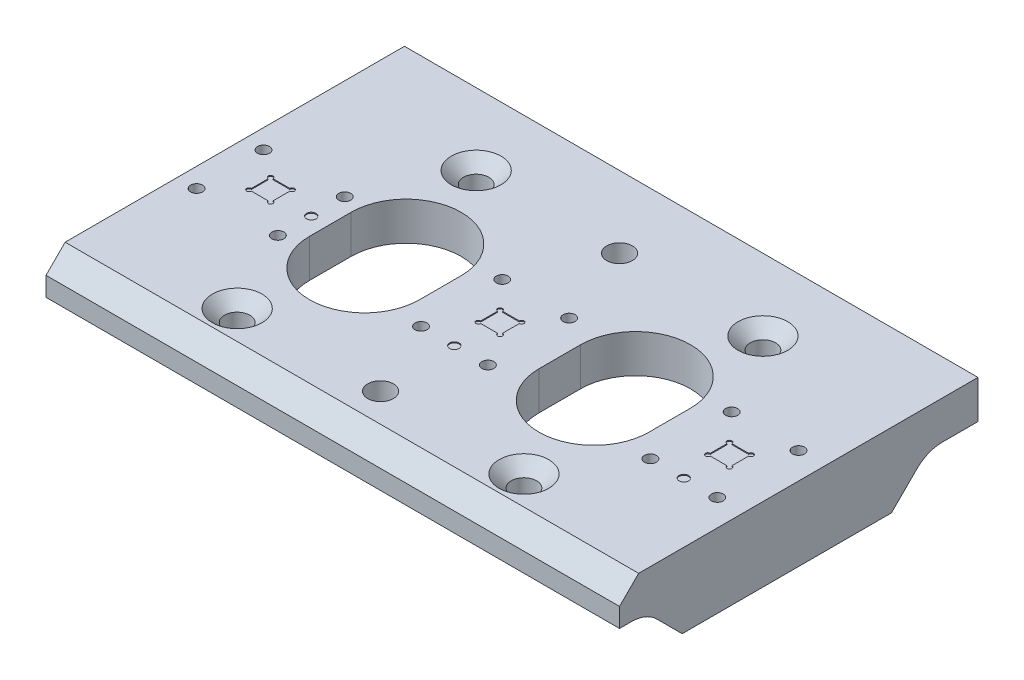
from build123d import *

# Parameters (mm, degrees)
SKETCH_5_W                  = 120
SKETCH_5_H                  = 75
EXTRUDE_2_DEPTH             = 8
SKETCH2_R                   = 1
CUT_EXTRUDE2_DEPTH          = 0.2
M3X0_5_TAPPED_HOLE1_D       = 2.5
M3X0_5_TAPPED_HOLE1_DEPTH   = 5.5
M3X0_5_TAPPED_HOLE1_TIP     = 0.751075774
HOLE_WIZARD_M51_D           = 5.3
HOLE_WIZARD_M51_CSINK_D     = 10.4
HOLE_WIZARD_M51_CSINK_ANGLE = 90
SKETCH5_R                   = 2.6
CUT_EXTRUDE3_DEPTH          = 9
CUT_EXTRUDE3_TAPER          = -0.573055556
CUT_EXTRUDE_1_DEPTH         = 10
EXTRUDE_3_DEPTH             = 120
SKETCH_8_W                  = 92
SKETCH_8_H                  = 31.175411479
CUT_EXTRUDE_2_DEPTH         = 76
CHAMFER_1_SIZE              = 4


with BuildPart() as part:
    # Эскиз5 → Бобышка-Вытянуть2 (new body)
    with BuildSketch(Plane(origin=(0, 0, 0), x_dir=(1, 0, 0), z_dir=(0, 1, 0))):
        with Locations((60, 2.5)):
            Rectangle(SKETCH_5_W, SKETCH_5_H)
    extrude(amount=-EXTRUDE_2_DEPTH)

    # Sketch2 → Cut-Extrude2 (cut)
    with BuildSketch(Plane(origin=(0, 0, 0), x_dir=(1, 0, 0), z_dir=(0, 1, 0))):
        with Locations((59.481, -9.027)):
            Circle(SKETCH2_R)
        with Locations((21.027, -0.519)):
            Circle(SKETCH2_R)
        with Locations((107.481, -9.027)):
            Circle(SKETCH2_R)
        with BuildLine():
            Line((106.24, -2.26), (109.76, -2.26))
            ThreePointArc((109.76, -2.26), (110.613553391, -2.613553391), (110.26, -1.76))
            Line((110.26, -1.76), (110.26, 1.76))
            ThreePointArc((110.26, 1.76), (110.613553391, 2.613553391), (109.76, 2.26))
            Line((109.76, 2.26), (106.24, 2.26))
            ThreePointArc((106.24, 2.26), (105.386446609, 2.613553391), (105.74, 1.76))
            Line((105.74, 1.76), (105.74, -1.76))
            ThreePointArc((105.74, -1.76), (105.386446609, -2.613553391), (106.24, -2.26))
        make_face()
        with BuildLine():
            Line((58.24, -2.26), (61.76, -2.26))
            ThreePointArc((61.76, -2.26), (62.613553391, -2.613553391), (62.26, -1.76))
            Line((62.26, -1.76), (62.26, 1.76))
            ThreePointArc((62.26, 1.76), (62.613553391, 2.613553391), (61.76, 2.26))
            Line((61.76, 2.26), (58.24, 2.26))
            ThreePointArc((58.24, 2.26), (57.386446609, 2.613553391), (57.74, 1.76))
            Line((57.74, 1.76), (57.74, -1.76))
            ThreePointArc((57.74, -1.76), (57.386446609, -2.613553391), (58.24, -2.26))
        make_face()
        with BuildLine():
            Line((10.24, -2.26), (13.76, -2.26))
            ThreePointArc((13.76, -2.26), (14.613553391, -2.613553391), (14.26, -1.76))
            Line((14.26, -1.76), (14.26, 1.76))
            ThreePointArc((14.26, 1.76), (14.613553391, 2.613553391), (13.76, 2.26))
            Line((13.76, 2.26), (10.24, 2.26))
            ThreePointArc((10.24, 2.26), (9.386446609, 2.613553391), (9.74, 1.76))
            Line((9.74, 1.76), (9.74, -1.76))
            ThreePointArc((9.74, -1.76), (9.386446609, -2.613553391), (10.24, -2.26))
        make_face()
    extrude(amount=-CUT_EXTRUDE2_DEPTH, mode=Mode.SUBTRACT)

    # M3x0.5 Tapped Hole1
    with Locations(Plane(origin=(0, 0, 0), x_dir=(1, 0, 0), z_dir=(0, 1, 0))):
        with Locations((21.027, 6.481), (4.027, 6.481), (4.027, -7.519), (21.027, -7.519), (52.481, 7.973), (66.481, 7.973), (66.481, -9.027), (52.481, -9.027), (100.481, -9.027), (114.481, -9.027), (114.481, 7.973), (100.481, 7.973)):
            Hole(M3X0_5_TAPPED_HOLE1_D / 2, depth=M3X0_5_TAPPED_HOLE1_DEPTH)
            with Locations((0, 0, -(M3X0_5_TAPPED_HOLE1_DEPTH + M3X0_5_TAPPED_HOLE1_TIP / 2))):  # 118° drill point
                Cone(0, M3X0_5_TAPPED_HOLE1_D / 2, M3X0_5_TAPPED_HOLE1_TIP, mode=Mode.SUBTRACT)

    # Зенковка для  винта с плоской головкой M51 (through all)
    with Locations(Plane(origin=(0, 0, 0), x_dir=(1, 0, 0), z_dir=(0, 1, 0))):
        with Locations((30, 25), (90, 25), (90, -25), (30, -25)):
            CounterSinkHole(HOLE_WIZARD_M51_D / 2, HOLE_WIZARD_M51_CSINK_D / 2, counter_sink_angle=HOLE_WIZARD_M51_CSINK_ANGLE)

    # Sketch5 → Cut-Extrude3 (cut, through all)
    with BuildSketch(Plane.XZ.offset(8)):
        with Locations((60, 25)):
            Circle(SKETCH5_R)
        with Locations((60, -25)):
            Circle(SKETCH5_R)
    extrude(amount=-CUT_EXTRUDE3_DEPTH, taper=CUT_EXTRUDE3_TAPER, mode=Mode.SUBTRACT)

    # Эскиз6 → Вырез-Вытянуть1 (cut)
    with BuildSketch(Plane(origin=(0, 0, 0), x_dir=(1, 0, 0), z_dir=(0, 1, 0))):
        with BuildLine():
            Line((95.5, 4.354177178), (95.5, -4.354177178))
            ThreePointArc((95.5, -4.354177178), (84, -15.854177178), (72.5, -4.354177178))
            Line((72.5, -4.354177178), (72.5, 4.354177178))
            ThreePointArc((72.5, 4.354177178), (84, 15.854177178), (95.5, 4.354177178))
        make_face()
        with BuildLine():
            Line((47.5, 4.354177178), (47.5, -4.354177178))
            ThreePointArc((47.5, -4.354177178), (36, -15.854177178), (24.5, -4.354177178))
            Line((24.5, -4.354177178), (24.5, 4.354177178))
            ThreePointArc((24.5, 4.354177178), (36, 15.854177178), (47.5, 4.354177178))
        make_face()
    extrude(amount=-CUT_EXTRUDE_1_DEPTH, mode=Mode.SUBTRACT)

    # Эскиз7 → Бобышка-Вытянуть3 (add, through all)
    with BuildSketch(Plane.ZY):
        with BuildLine():
            Line((-32.5, -8), (32.5, -8))
            ThreePointArc((32.5, -8), (29.629874257, -8.570903506), (27.196699141, -10.196699141))
            Line((27.196699141, -10.196699141), (21.893398282, -15.5))
            Line((21.893398282, -15.5), (-21.893398282, -15.5))
            Line((-21.893398282, -15.5), (-27.196699141, -10.196699141))
            ThreePointArc((-27.196699141, -10.196699141), (-29.629874257, -8.570903506), (-32.5, -8))
        make_face()
    extrude(amount=-EXTRUDE_3_DEPTH)

    # Эскиз8 → Вырез-Вытянуть2 (cut, through all)
    with BuildSketch(Plane.XY.offset(35)):
        with Locations((60, -23.58770574)):
            Rectangle(SKETCH_8_W, SKETCH_8_H)
    extrude(amount=-CUT_EXTRUDE_2_DEPTH, mode=Mode.SUBTRACT)

    # Фаска1
    chamfer_1_edges = [part.edges().sort_by_distance(p)[0] for p in [
        (60, 0, 35),
    ]]
    chamfer(chamfer_1_edges, length=CHAMFER_1_SIZE)


solid = part.part
